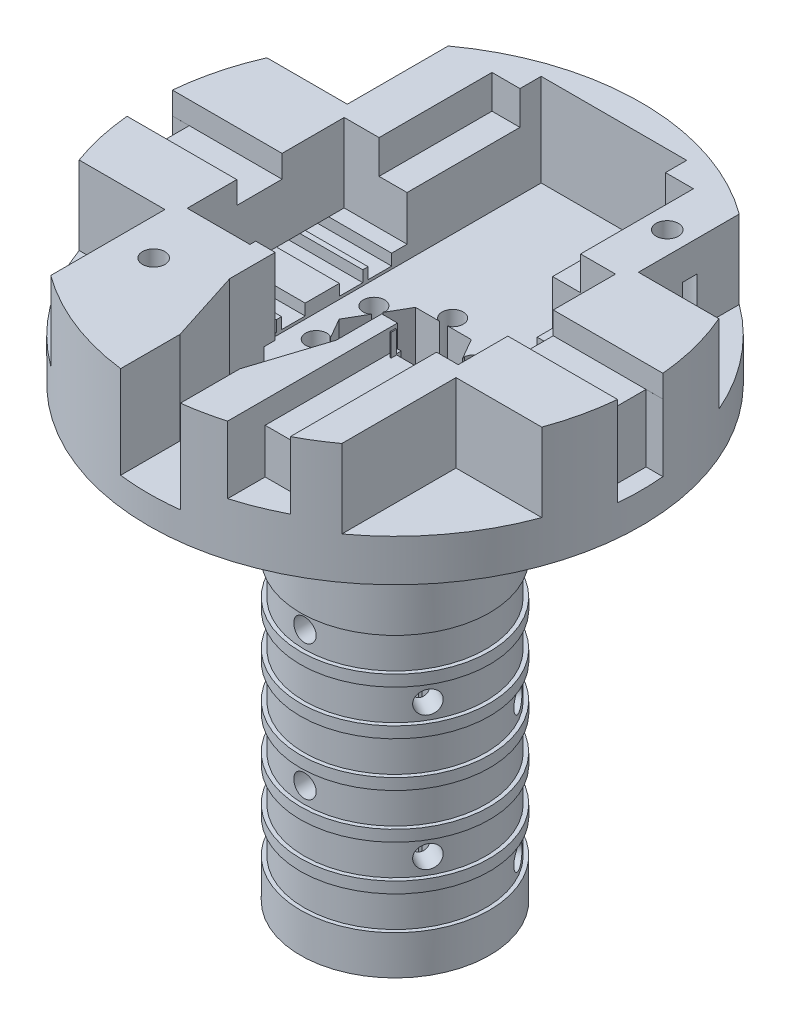
from build123d import *
from build123d.topology import SkipClean

# Parameters (mm, degrees)
BOSS_EXTRUDE1_DEPTH      = 8.75
BOSS_EXTRUDE1_DEPTH_BACK = 2
SKETCH1_R                = 22
SKETCH6_R                = 21
SKETCH6_R_2              = 12.5
CUT_EXTRUDE5_DEPTH       = 1
SKETCH7_R                = 8.5
BOSS_EXTRUDE2_DEPTH      = 40
CUT_EXTRUDE6_DEPTH       = 51.675437837
CUT_EXTRUDE6_DEPTH_BACK  = 51.675437837
SKETCH8_R                = 1.5
CUT_EXTRUDE7_DEPTH       = 7
CUT_EXTRUDE14_DEPTH      = 62
SKETCH29_W               = 18
SKETCH29_H               = 24.118038922
CUT_EXTRUDE19_DEPTH      = 3
SKETCH30_W               = 2.5
SKETCH30_H               = 14
CUT_EXTRUDE20_DEPTH      = 6
BOSS_EXTRUDE4_DEPTH      = 2
BOSS_EXTRUDE4_DEPTH_BACK = 2
SKETCH35_R               = 9.1
SKETCH35_R_2             = 8.5
CUT_EXTRUDE28_DEPTH      = 1.5
CUT_EXTRUDE28_DEPTH_BACK = 1.5
SKETCH36_R               = 8.5
SKETCH36_R_2             = 8.1
CUT_EXTRUDE30_DEPTH      = 1.5
CUT_EXTRUDE30_DEPTH_BACK = 1.5
SKETCH39_R               = 8.5
SKETCH39_R_2             = 8.1
CUT_EXTRUDE31_DEPTH      = 1.5
CUT_EXTRUDE31_DEPTH_BACK = 1.5
SKETCH40_R               = 8.5
SKETCH40_R_2             = 8.1
CUT_EXTRUDE32_DEPTH      = 1.5
CUT_EXTRUDE32_DEPTH_BACK = 1.5
SKETCH41_R               = 8.5
SKETCH41_R_2             = 8.1
CUT_EXTRUDE33_DEPTH      = 1.5
CUT_EXTRUDE33_DEPTH_BACK = 1.5
SKETCH42_R               = 8.5
SKETCH42_R_2             = 8.1
CUT_EXTRUDE34_DEPTH      = 1.5
CUT_EXTRUDE34_DEPTH_BACK = 1.5
SKETCH43_R               = 8.5
SKETCH43_R_2             = 8.1
CUT_EXTRUDE35_DEPTH      = 53.268537381
CUT_EXTRUDE35_DEPTH_BACK = 53.268537381
SKETCH44_R               = 1
CUT_EXTRUDE36_DEPTH      = 53.268537462
CUT_EXTRUDE36_DEPTH_BACK = 53.268537462
SKETCH45_R               = 1
CUT_EXTRUDE37_DEPTH      = 53.268537462
CUT_EXTRUDE37_DEPTH_BACK = 53.268537462
SKETCH46_R               = 1
SKETCH47_W               = 27.732128476
SKETCH47_H               = 14.033639909
CUT_EXTRUDE38_DEPTH      = 7
CUT_EXTRUDE39_DEPTH      = 8.25
SKETCH48_R               = 1
CUT_EXTRUDE40_DEPTH      = 9
SKETCH50_R               = 6.388253867
BOSS_EXTRUDE5_DEPTH      = 2
SKETCH49_R               = 2.1
CUT_EXTRUDE42_DEPTH      = 7
SKETCH51_W               = 35.63730279
SKETCH51_H               = 2.1
CUT_EXTRUDE43_DEPTH      = 1
CUT_EXTRUDE44_DEPTH      = 2
CUT_EXTRUDE45_START      = -33.5
SKETCH53_R               = 8.5
SKETCH53_R_2             = 8.45
CUT_EXTRUDE45_DEPTH      = 33.5
CUT_EXTRUDE46_DEPTH      = 6
SKETCH55_W               = 1.737607108
SKETCH55_H               = 6.804348591
BOSS_EXTRUDE6_DEPTH      = 1
BOSS_EXTRUDE7_DEPTH      = 7
SKETCH58_W               = 10.391700465
SKETCH58_H               = 4.050234679
CUT_EXTRUDE47_DEPTH      = 2
CUT_EXTRUDE48_DEPTH      = 8


with BuildPart() as part:
    # Sketch1 → Boss-Extrude1 (new, two sides: drawn at the far end of the back side and taken through both)
    with BuildSketch(Plane(origin=(0, 0, 0), x_dir=(1, 0, 0), z_dir=(0, 1, 0)).offset(-BOSS_EXTRUDE1_DEPTH_BACK)):
        Circle(SKETCH1_R)
    extrude(amount=BOSS_EXTRUDE1_DEPTH + BOSS_EXTRUDE1_DEPTH_BACK)

    # Sketch6 → Cut-Extrude5 (cut)
    with BuildSketch(Plane(origin=(0, -2, 0), x_dir=(-1, 0, 0), z_dir=(0, -1, 0))):
        Circle(SKETCH6_R)
        Circle(SKETCH6_R_2, mode=Mode.SUBTRACT)
    extrude(amount=-CUT_EXTRUDE5_DEPTH, mode=Mode.SUBTRACT)

    # Sketch7 → Boss-Extrude2 (add)
    with BuildSketch(Plane(origin=(0, -2, 0), x_dir=(-1, 0, 0), z_dir=(0, -1, 0))):
        Circle(SKETCH7_R)
    extrude(amount=BOSS_EXTRUDE2_DEPTH)

    # Sketch8 → Cut-Extrude6 (cut, two sides: drawn at the far end of the back side and taken through both)
    with BuildSketch(Plane(origin=(0, -2, 0), x_dir=(-1, 0, 0), z_dir=(0, -1, 0)).offset(-CUT_EXTRUDE6_DEPTH_BACK)):
        Circle(SKETCH8_R)
    extrude(amount=CUT_EXTRUDE6_DEPTH + CUT_EXTRUDE6_DEPTH_BACK, mode=Mode.SUBTRACT)

    # Sketch9 → Cut-Extrude7 (cut)
    with BuildSketch(Plane(origin=(0, 8.75, 0), x_dir=(1, 0, 0), z_dir=(0, 1, 0))):
        with BuildLine():
            Line((-13.000713231, -20.359249211), (-13.000713231, 20.359249211))
            ThreePointArc((-13.000713231, 20.359249211), (-24.156108398, 0), (-13.000713231, -20.359249211))
        make_face()
        with BuildLine():
            Line((13, -20.359704638), (13, 20.359704638))
            ThreePointArc((13, 20.359704638), (24.156108398, 0), (13, -20.359704638))
        make_face()
    extrude(amount=-CUT_EXTRUDE7_DEPTH, mode=Mode.SUBTRACT)

    # Sketch17 → Cut-Extrude14 (cut)
    with BuildSketch(Plane(origin=(0, -42, 0), x_dir=(-1, 0, 0), z_dir=(0, -1, 0))):
        with BuildLine():
            Line((3.510112493, 2.562543944), (2.49433043, 4.321460529))
            Line((2.49433043, 4.321460529), (0.464363513, 4.321225889))
            Line((0.464363513, 4.321225889), (0.364363514, 4.32121433))
            Line((0.364363514, 4.32121433), (0.572663129, 4.392004656))
            ThreePointArc((0.572663129, 4.392004656), (-0.000109809, 6.099999994), (-0.572487883, 4.39187229))
            Line((-0.572487883, 4.39187229), (-0.364171908, 4.321130119))
            Line((-0.364171908, 4.321130119), (-0.464171907, 4.321118561))
            Line((-0.464171907, 4.321118561), (-2.495329385, 4.320883782))
            Line((-2.495329385, 4.320883782), (-3.510109638, 2.562763543))
            Line((-3.510109638, 2.562763543), (-3.560099628, 2.476155224))
            Line((-3.560099628, 2.476155224), (-3.517256042, 2.691943146))
            ThreePointArc((-3.517256042, 2.691943146), (-5.282809862, 3.049904899), (-4.089716915, 1.700147095))
            Line((-4.089716915, 1.700147095), (-3.924294411, 1.845182936))
            Line((-3.924294411, 1.845182936), (-3.9742844, 1.758574617))
            Line((-3.9742844, 1.758574617), (-4.989659815, -0.000576747))
            Line((-4.989659815, -0.000576747), (-3.974473152, -1.758462345))
            Line((-3.974473152, -1.758462345), (-3.924463142, -1.845059106))
            Line((-3.924463142, -1.845059106), (-4.08991917, -1.700061511))
            ThreePointArc((-4.08991917, -1.700061511), (-5.282700053, -3.050095094), (-3.517229032, -2.691725195))
            Line((-3.517229032, -2.691725195), (-3.560122503, -2.475947183))
            Line((-3.560122503, -2.475947183), (-3.510112493, -2.562543944))
            Line((-3.510112493, -2.562543944), (-2.49433043, -4.321460529))
            Line((-2.49433043, -4.321460529), (-0.464363513, -4.321225889))
            Line((-0.464363513, -4.321225889), (-0.364363514, -4.32121433))
            Line((-0.364363514, -4.32121433), (-0.572663129, -4.392004656))
            ThreePointArc((-0.572663129, -4.392004656), (0.000109809, -6.099999994), (0.572487883, -4.39187229))
            Line((0.572487883, -4.39187229), (0.364171908, -4.321130119))
            Line((0.364171908, -4.321130119), (0.464171907, -4.321118561))
            Line((0.464171907, -4.321118561), (2.495329385, -4.320883782))
            Line((2.495329385, -4.320883782), (3.510109638, -2.562763543))
            Line((3.510109638, -2.562763543), (3.560099628, -2.476155224))
            Line((3.560099628, -2.476155224), (3.517256042, -2.691943146))
            ThreePointArc((3.517256042, -2.691943146), (5.282809862, -3.049904899), (4.089716915, -1.700147095))
            Line((4.089716915, -1.700147095), (3.924294411, -1.845182936))
            Line((3.924294411, -1.845182936), (3.9742844, -1.758574617))
            Line((3.9742844, -1.758574617), (4.989659815, 0.000576747))
            Line((4.989659815, 0.000576747), (3.974473152, 1.758462345))
            Line((3.974473152, 1.758462345), (3.924463142, 1.845059106))
            Line((3.924463142, 1.845059106), (4.08991917, 1.700061511))
            ThreePointArc((4.08991917, 1.700061511), (5.282700053, 3.050095094), (3.517229032, 2.691725195))
            Line((3.517229032, 2.691725195), (3.560122503, 2.475947183))
            Line((3.560122503, 2.475947183), (3.510112493, 2.562543944))
        make_face()
    extrude(amount=-CUT_EXTRUDE14_DEPTH, mode=Mode.SUBTRACT)

    # Sketch29 → Cut-Extrude19 (cut)
    with BuildSketch(Plane(origin=(0, 8.75, 0), x_dir=(1, 0, 0), z_dir=(0, 1, 0))):
        with Locations((0, 5.603215798)):
            Rectangle(SKETCH29_W, SKETCH29_H)
    extrude(amount=-CUT_EXTRUDE19_DEPTH, mode=Mode.SUBTRACT)

    # Sketch30 → Cut-Extrude20 (cut)
    with BuildSketch(Plane(origin=(0, 8.75, 0), x_dir=(1, 0, 0), z_dir=(0, 1, 0))):
        with Locations((6.752146467, 0.544196337)):
            Rectangle(SKETCH30_W, SKETCH30_H)
        with Locations((-6.752146467, 0.544196337)):
            Rectangle(SKETCH30_W, SKETCH30_H)
    extrude(amount=-CUT_EXTRUDE20_DEPTH, mode=Mode.SUBTRACT)

    # Sketch35 → Boss-Extrude4 (add, two sides: drawn at the far end of the back side and taken through both)
    with BuildSketch(Plane(origin=(0, -6.5, 0), x_dir=(1, 0, 0), z_dir=(0, 1, 0)).offset(-BOSS_EXTRUDE4_DEPTH_BACK)):
        Circle(SKETCH35_R)
        Circle(SKETCH35_R_2, mode=Mode.SUBTRACT)
    extrude(amount=BOSS_EXTRUDE4_DEPTH + BOSS_EXTRUDE4_DEPTH_BACK)

    # Sketch36 → Cut-Extrude28 (cut, two sides: drawn at the far end of the back side and taken through both)
    with BuildSketch(Plane(origin=(0, -17, 0), x_dir=(1, 0, 0), z_dir=(0, 1, 0)).offset(-CUT_EXTRUDE28_DEPTH_BACK)):
        Circle(SKETCH36_R)
        Circle(SKETCH36_R_2, mode=Mode.SUBTRACT)
    extrude(amount=CUT_EXTRUDE28_DEPTH + CUT_EXTRUDE28_DEPTH_BACK, mode=Mode.SUBTRACT)

    # Sketch39 → Cut-Extrude30 (cut, two sides: drawn at the far end of the back side and taken through both)
    with BuildSketch(Plane(origin=(0, -21, 0), x_dir=(1, 0, 0), z_dir=(0, 1, 0)).offset(-CUT_EXTRUDE30_DEPTH_BACK)):
        Circle(SKETCH39_R)
        Circle(SKETCH39_R_2, mode=Mode.SUBTRACT)
    extrude(amount=CUT_EXTRUDE30_DEPTH + CUT_EXTRUDE30_DEPTH_BACK, mode=Mode.SUBTRACT)

    # Sketch40 → Cut-Extrude31 (cut, two sides: drawn at the far end of the back side and taken through both)
    with BuildSketch(Plane(origin=(0, -25, 0), x_dir=(1, 0, 0), z_dir=(0, 1, 0)).offset(-CUT_EXTRUDE31_DEPTH_BACK)):
        Circle(SKETCH40_R)
        Circle(SKETCH40_R_2, mode=Mode.SUBTRACT)
    extrude(amount=CUT_EXTRUDE31_DEPTH + CUT_EXTRUDE31_DEPTH_BACK, mode=Mode.SUBTRACT)

    # Sketch41 → Cut-Extrude32 (cut, two sides: drawn at the far end of the back side and taken through both)
    with BuildSketch(Plane(origin=(0, -29, 0), x_dir=(1, 0, 0), z_dir=(0, 1, 0)).offset(-CUT_EXTRUDE32_DEPTH_BACK)):
        Circle(SKETCH41_R)
        Circle(SKETCH41_R_2, mode=Mode.SUBTRACT)
    extrude(amount=CUT_EXTRUDE32_DEPTH + CUT_EXTRUDE32_DEPTH_BACK, mode=Mode.SUBTRACT)

    # Sketch42 → Cut-Extrude33 (cut, two sides: drawn at the far end of the back side and taken through both)
    with BuildSketch(Plane(origin=(0, -33, 0), x_dir=(1, 0, 0), z_dir=(0, 1, 0)).offset(-CUT_EXTRUDE33_DEPTH_BACK)):
        Circle(SKETCH42_R)
        Circle(SKETCH42_R_2, mode=Mode.SUBTRACT)
    extrude(amount=CUT_EXTRUDE33_DEPTH + CUT_EXTRUDE33_DEPTH_BACK, mode=Mode.SUBTRACT)

    # Sketch43 → Cut-Extrude34 (cut, two sides: drawn at the far end of the back side and taken through both)
    with BuildSketch(Plane(origin=(0, -37, 0), x_dir=(1, 0, 0), z_dir=(0, 1, 0)).offset(-CUT_EXTRUDE34_DEPTH_BACK)):
        Circle(SKETCH43_R)
        Circle(SKETCH43_R_2, mode=Mode.SUBTRACT)
    extrude(amount=CUT_EXTRUDE34_DEPTH + CUT_EXTRUDE34_DEPTH_BACK, mode=Mode.SUBTRACT)

    # Sketch44 → Cut-Extrude35 (cut, two sides: drawn at the far end of the back side and taken through both)
    with BuildSketch(Plane.XY.offset(-CUT_EXTRUDE35_DEPTH_BACK)):
        with Locations((0, -16.975647938)):
            Circle(SKETCH44_R)
        with Locations((0, -29.042179734)):
            Circle(SKETCH44_R)
    extrude(amount=CUT_EXTRUDE35_DEPTH + CUT_EXTRUDE35_DEPTH_BACK, mode=Mode.SUBTRACT)

    # Sketch45 → Cut-Extrude36 (cut, two sides: drawn at the far end of the back side and taken through both)
    with BuildSketch(Plane(origin=(0, 0, 0), x_dir=(0, 1, 0), z_dir=(0.8660254037844398, 0, 0.499999999999998)).offset(-CUT_EXTRUDE36_DEPTH_BACK)):
        with Locations((-21.101513607, 0)):
            Circle(SKETCH45_R)
        with Locations((-33.049455879, 0)):
            Circle(SKETCH45_R)
    extrude(amount=CUT_EXTRUDE36_DEPTH + CUT_EXTRUDE36_DEPTH_BACK, mode=Mode.SUBTRACT)

    # Sketch46 → Cut-Extrude37 (cut, two sides: drawn at the far end of the back side and taken through both)
    with BuildSketch(Plane(origin=(0, 0, 0), x_dir=(0, 1, 0), z_dir=(0.8660254037844364, 0, -0.500000000000004)).offset(-CUT_EXTRUDE37_DEPTH_BACK)):
        with Locations((-24.961001523, 0)):
            Circle(SKETCH46_R)
        with Locations((-37.130366549, 0)):
            Circle(SKETCH46_R)
    extrude(amount=CUT_EXTRUDE37_DEPTH + CUT_EXTRUDE37_DEPTH_BACK, mode=Mode.SUBTRACT)

    # Sketch47 → Cut-Extrude38 (cut)
    with BuildSketch(Plane(origin=(0, 8.75, 0), x_dir=(1, 0, 0), z_dir=(0, 1, 0))):
        with Locations((-0.011675811, 0.561016292)):
            Rectangle(SKETCH47_W, SKETCH47_H)
    extrude(amount=-CUT_EXTRUDE38_DEPTH, mode=Mode.SUBTRACT)

    # Sketch23 → Cut-Extrude39 (cut)
    with BuildSketch(Plane(origin=(0, 8.75, 0), x_dir=(1, 0, 0), z_dir=(0, 1, 0))):
        with BuildLine():
            Line((-2.670420152, -16.85816067), (-2.670420152, -16.530371213))
            Line((-2.670420152, -16.530371213), (-4.762392892, -10))
            Line((-4.762392892, -10), (-4.762392892, -6.943148259))
            Line((-4.762392892, -6.943148259), (-6.5, -6.943148259))
            Line((-6.5, -6.943148259), (-6.5, 19.556851741))
            Line((-6.5, 19.556851741), (6.5, 19.556851741))
            Line((6.5, 19.556851741), (6.5, -6.943148259))
            Line((6.5, -6.943148259), (4.762392892, -6.943148259))
            Line((4.762392892, -6.943148259), (4.762392892, -10))
            Line((4.762392892, -10), (2.670420152, -16.530371213))
            Line((2.670420152, -16.530371213), (2.670420152, -16.85816067))
            Line((2.670420152, -16.85816067), (2.670420152, -21.837327131))
            ThreePointArc((2.670420152, -21.837327131), (1.836835043, -21.92318492), (1.000584871, -21.977234355))
            Line((1.000584871, -21.977234355), (0, -25.25))
            Line((0, -25.25), (-1.000584871, -21.977234355))
            ThreePointArc((-1.000584871, -21.977234355), (-1.836835043, -21.92318492), (-2.670420152, -21.837327131))
            Line((-2.670420152, -21.837327131), (-2.670420152, -16.85816067))
        make_face()
    extrude(amount=-CUT_EXTRUDE39_DEPTH, mode=Mode.SUBTRACT)

    # Sketch48 → Cut-Extrude40 (cut)
    with BuildSketch(Plane(origin=(0, 8.75, 0), x_dir=(1, 0, 0), z_dir=(0, 1, 0))):
        with Locations((11, 13.315197565)):
            Circle(SKETCH48_R)
        with Locations((-9.750356615, -11.802538605)):
            Circle(SKETCH48_R)
    extrude(amount=-CUT_EXTRUDE40_DEPTH, mode=Mode.SUBTRACT)

    # Sketch50 → Boss-Extrude5 (add)
    with BuildSketch(Plane.XZ.offset(42)):
        Circle(SKETCH50_R)
        Polygon((-4.989659815, -0.000576747), (-2.49433043, -4.321460529), (2.495329385, -4.320883782), (4.989659815, 0.000576747), (2.49433043, 4.321460529), (-2.495329385, 4.320883782), align=None, mode=Mode.SUBTRACT)
    extrude(amount=-BOSS_EXTRUDE5_DEPTH)

    # Sketch49 → Cut-Extrude42 (cut)
    with BuildSketch(Plane.XZ.offset(1)):
        with Locations((-9.750356615, 11.802538605)):
            Circle(SKETCH49_R)
        with Locations((11, -13.315197565)):
            Circle(SKETCH49_R)
    extrude(amount=-CUT_EXTRUDE42_DEPTH, mode=Mode.SUBTRACT)

    # Sketch51 → Cut-Extrude43 (cut)
    with BuildSketch(Plane(origin=(0, 1.75, 0), x_dir=(1, 0, 0), z_dir=(0, 1, 0))):
        with Locations((0, 5.15)):
            Rectangle(SKETCH51_W, SKETCH51_H)
        with Locations((0, 2.575)):
            Rectangle(SKETCH51_W, SKETCH51_H)
        with Locations((0, -2.575)):
            Rectangle(SKETCH51_W, SKETCH51_H)
        with Locations((0, -5.15)):
            Rectangle(SKETCH51_W, SKETCH51_H)
    extrude(amount=-CUT_EXTRUDE43_DEPTH, mode=Mode.SUBTRACT)

    # Sketch52 → Cut-Extrude44 (cut)
    with BuildSketch(Plane(origin=(0, 8.75, 0), x_dir=(1, 0, 0), z_dir=(0, 1, 0))):
        Polygon((6.167287474, -17.764425584), (10.167287474, -17.764425584), (10.167287474, -6.455803663), (6.6, -6.455803663), (6.6, -6.943148259), (6.167287474, -6.943148259), align=None)
    extrude(amount=-CUT_EXTRUDE44_DEPTH, mode=Mode.SUBTRACT)

    # Sketch53 → Cut-Extrude45 (cut)
    with BuildSketch(Plane.XZ.offset(42).offset(CUT_EXTRUDE45_START)):
        Circle(SKETCH53_R)
        Circle(SKETCH53_R_2, mode=Mode.SUBTRACT)
    extrude(amount=CUT_EXTRUDE45_DEPTH, mode=Mode.SUBTRACT)

    # Sketch54 → Cut-Extrude46 (cut)
    with BuildSketch(Plane(origin=(0, 8.75, 0), x_dir=(1, 0, 0), z_dir=(0, 1, 0))):
        with BuildLine():
            Line((10.167287474, -19.509645446), (10.167287474, -17.764425584))
            Line((10.167287474, -17.764425584), (6.167287474, -17.764425584))
            Line((6.167287474, -17.764425584), (6.167287474, -21.117873122))
            ThreePointArc((6.167287474, -21.117873122), (8.206776697, -20.411977274), (10.167287474, -19.509645446))
        make_face()
    extrude(amount=-CUT_EXTRUDE46_DEPTH, mode=Mode.SUBTRACT)

    # Sketch55 → Boss-Extrude6 (add)
    with BuildSketch(Plane(origin=(0, 0, 6.943148259), x_dir=(-1, 0, 0), z_dir=(0, 0, -1))):
        Polygon((-4.762392892, 8.75), (-6.167287474, 8.75), (-6.167287474, 6.75), (-6.5, 6.75), (-6.5, 1.945651409), (-4.762392892, 1.945651409), align=None)
        with Locations((5.631196446, 5.347825704)):
            Rectangle(SKETCH55_W, SKETCH55_H)
    extrude(amount=BOSS_EXTRUDE6_DEPTH)

    # Sketch56 → Boss-Extrude7 (add)
    with BuildSketch(Plane(origin=(0, 1.75, 0), x_dir=(1, 0, 0), z_dir=(0, 1, 0))):
        with BuildLine():
            Line((12.101760893, -7.551650053), (12.119041539, 8.742214933))
            Line((12.119041539, 8.742214933), (20.188454078, 8.742214933))
            ThreePointArc((20.188454078, 8.742214933), (21.990663147, 0.640885619), (20.663314871, -7.551650053))
            Line((20.663314871, -7.551650053), (12.101760893, -7.551650053))
        make_face()
    boss_extrude7 = extrude(amount=BOSS_EXTRUDE7_DEPTH)

    # Sketch58 → Cut-Extrude47 (cut)
    with BuildSketch(Plane(origin=(0, 8.75, 0), x_dir=(1, 0, 0), z_dir=(0, 1, 0))):
        with Locations((17.142055977, -0.001385241)):
            Rectangle(SKETCH58_W, SKETCH58_H)
    cut_extrude47 = extrude(amount=-CUT_EXTRUDE47_DEPTH, mode=Mode.SUBTRACT)

    # Sketch59 → Cut-Extrude48 (cut)
    with SkipClean():  # the faces are left unmerged after this step: merging them gives an invalid solid
        with BuildSketch(Plane(origin=(0, 8.75, 0), x_dir=(1, 0, 0), z_dir=(0, 1, 0))):
            with BuildLine():
                Line((21.931481632, -2.027861721), (20.401348197, -2.027861721))
                Line((20.401348197, -2.027861721), (20.401348197, 2.022372958))
                Line((20.401348197, 2.022372958), (21.931481632, 2.022372958))
                ThreePointArc((21.931481632, 2.022372958), (22.02488674, -0.002744382), (21.931481632, -2.027861721))
            make_face()
        cut_extrude48 = extrude(amount=-CUT_EXTRUDE48_DEPTH, mode=Mode.SUBTRACT)

    # Mirror1: Boss-Extrude7, Cut-Extrude47, Cut-Extrude48 across plane
    with SkipClean():  # the faces are left unmerged after this step: merging them gives an invalid solid
        add(boss_extrude7.mirror(Plane(origin=(0, 0, 0), x_dir=(0, 0, 1), z_dir=(1, 0, 0))))
        add(cut_extrude47.mirror(Plane(origin=(0, 0, 0), x_dir=(0, 0, 1), z_dir=(1, 0, 0))), mode=Mode.SUBTRACT)
        add(cut_extrude48.mirror(Plane(origin=(0, 0, 0), x_dir=(0, 0, 1), z_dir=(1, 0, 0))), mode=Mode.SUBTRACT)


solid = part.part
